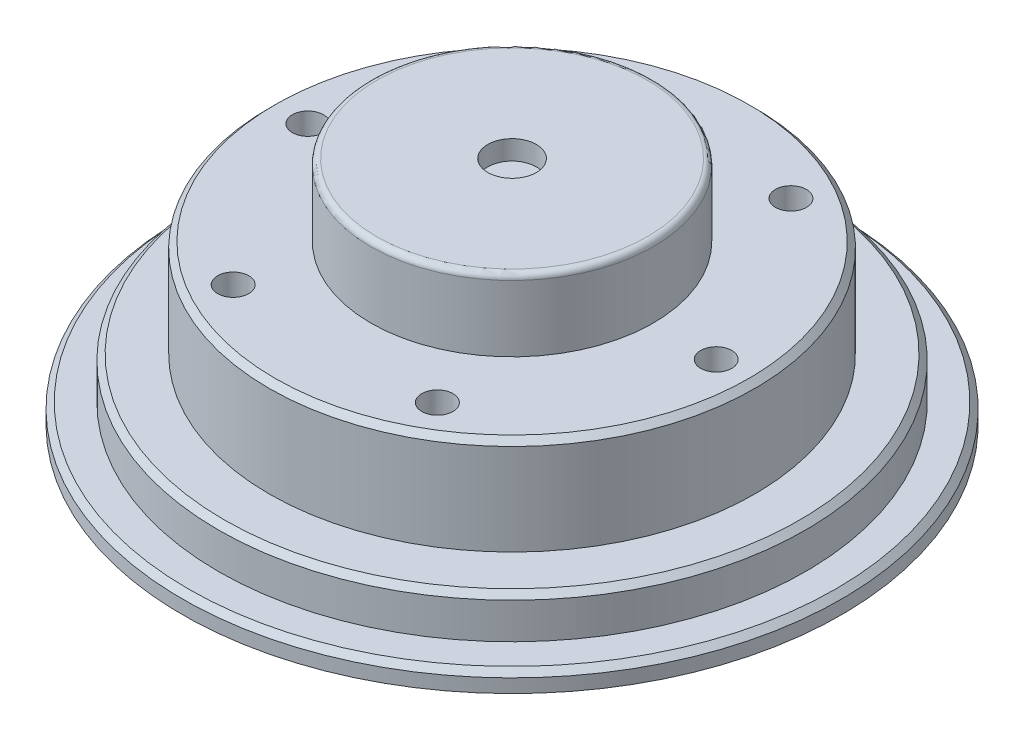
from build123d import *

# Parameters (mm, degrees)
SKETCH_1_R             = 15.1
EXTRUDE_1_DEPTH        = 2.15
SKETCH_2_R             = 12.49
EXTRUDE_2_DEPTH        = 5
SKETCH_3_R             = 7.265
EXTRUDE_3_DEPTH        = 3.7
SKETCH_4_R             = 16.95
EXTRUDE_4_DEPTH        = 1
SKETCH_5_R             = 1.25
CUT_EXTRUDE_1_DEPTH    = 1
FILLET_1_R             = 0.3
CHAMFER_1_SIZE         = 0.3
HOLE_WIZARD_M2_1_D     = 1.6
HOLE_WIZARD_M2_1_DEPTH = 5.2
HOLE_WIZARD_M2_1_TIP   = 0.480688495


with BuildPart() as part:
    # 草图1 → 凸台-拉伸1 (new body)
    with BuildSketch(Plane(origin=(0, 0, 0), x_dir=(1, 0, 0), z_dir=(0, 1, 0))):
        Circle(SKETCH_1_R)
    extrude(amount=EXTRUDE_1_DEPTH)

    # 草图2 → 凸台-拉伸2 (add)
    with BuildSketch(Plane(origin=(0, 2.15, 0), x_dir=(1, 0, 0), z_dir=(0, 1, 0))):
        Circle(SKETCH_2_R)
    extrude(amount=EXTRUDE_2_DEPTH)

    # 草图3 → 凸台-拉伸3 (add)
    with BuildSketch(Plane(origin=(0, 7.15, 0), x_dir=(1, 0, 0), z_dir=(0, 1, 0))):
        Circle(SKETCH_3_R)
    extrude(amount=EXTRUDE_3_DEPTH)

    # 草图4 → 凸台-拉伸4 (add)
    with BuildSketch(Plane(origin=(0, 0, 0), x_dir=(-1, 0, 0), z_dir=(0, -1, 0))):
        Circle(SKETCH_4_R)
    extrude(amount=EXTRUDE_4_DEPTH)

    # 草图5 → 切除-拉伸1 (cut)
    with BuildSketch(Plane(origin=(0, 10.85, 0), x_dir=(1, 0, 0), z_dir=(0, 1, 0))):
        Circle(SKETCH_5_R)
    extrude(amount=-CUT_EXTRUDE_1_DEPTH, mode=Mode.SUBTRACT)

    # 圆角1
    fillet_1_edges = [part.edges().sort_by_distance(p)[0] for p in [
        (-7.265, 10.85, 0),
    ]]
    fillet(fillet_1_edges, radius=FILLET_1_R)

    # 倒角1
    chamfer_1_edges = [part.edges().sort_by_distance(p)[0] for p in [
        (16.95, 0, 0),
        (-15.1, 2.15, 0),
        (-12.49, 7.15, 0),
    ]]
    chamfer(chamfer_1_edges, length=CHAMFER_1_SIZE)

    # M2 螺纹孔1
    with Locations(Plane(origin=(0, 7.15, 0), x_dir=(1, 0, 0), z_dir=(0, 1, 0))):
        with Locations((5.25, 9.09326674), (10.5, 0), (5.25, -9.09326674), (-5.25, -9.09326674), (-10.5, 0), (-5.25, 9.09326674)):
            Hole(HOLE_WIZARD_M2_1_D / 2, depth=HOLE_WIZARD_M2_1_DEPTH)
            with Locations((0, 0, -(HOLE_WIZARD_M2_1_DEPTH + HOLE_WIZARD_M2_1_TIP / 2))):  # 118° drill point
                Cone(0, HOLE_WIZARD_M2_1_D / 2, HOLE_WIZARD_M2_1_TIP, mode=Mode.SUBTRACT)


solid = part.part
